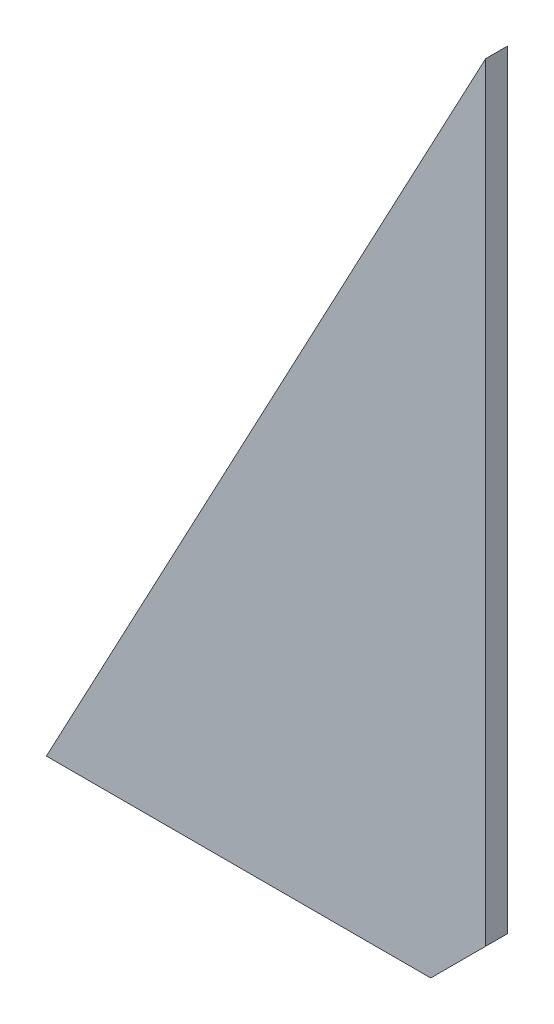
from build123d import *

# Parameters (mm, degrees)
BOSS_EXTRU_1_DEPTH = 2


with BuildPart() as part:
    # Esquisse1 → Boss.-Extru.1 (new body, symmetric)
    with BuildSketch(Plane.XY):
        Polygon((0, 0), (70, 0), (80, 10), (80, 150), align=None)
    extrude(amount=BOSS_EXTRU_1_DEPTH, both=True)


solid = part.part
